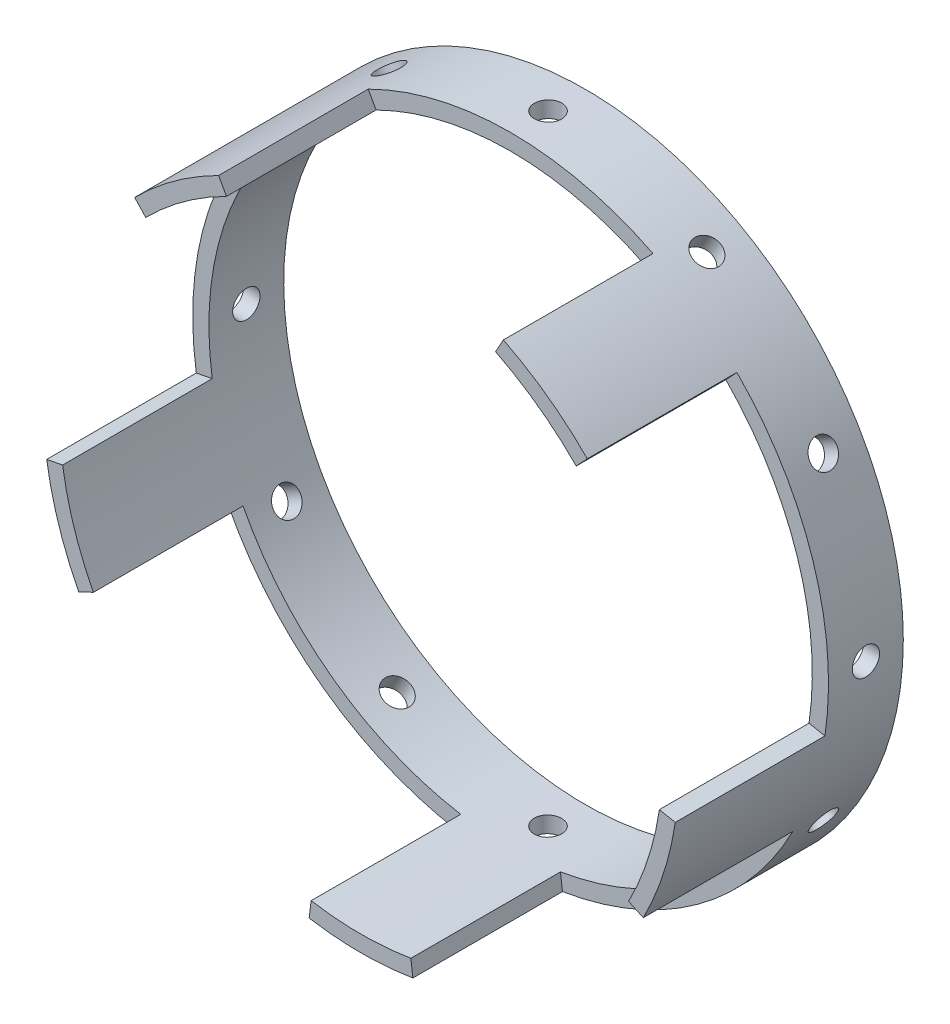
from build123d import *
from build123d.topology import SkipClean

# Parameters (mm, degrees)
SKETCH1_R           = 80.9625
SKETCH1_R_2         = 76.835
BOSS_EXTRUDE1_DEPTH = 19.05
BOSS_EXTRUDE2_DEPTH = 38.1
SKETCH2_R           = 3.478244762
CUT_EXTRUDE1_DEPTH  = 128.968649725
CIRPATTERN1_COUNT   = 12


with BuildPart() as part:
    # Sketch1 → Boss-Extrude1 (new body)
    with BuildSketch(Plane.XY):
        Circle(SKETCH1_R)
        Circle(SKETCH1_R_2, mode=Mode.SUBTRACT)
    extrude(amount=BOSS_EXTRUDE1_DEPTH)

    # Sketch3 → Boss-Extrude2 (add)
    with SkipClean():  # the faces are left unmerged after this step: merging them gives an invalid solid
        with BuildSketch(Plane.XY.offset(19.05)):
            with BuildLine():
                Line((-13.208, -79.877876426), (-12.7, -75.778144771))
                ThreePointArc((-12.7, -75.778144771), (0, -76.835), (12.7, -75.778144771))
                Line((12.7, -75.778144771), (13.208, -79.877876426))
                ThreePointArc((13.208, -79.877876426), (0, -80.9625), (-13.208, -79.877876426))
            make_face()
            with BuildLine():
                Line((-68.144782549, -35.495152294), (-71.886878421, -37.245175757))
                ThreePointArc((-71.886878421, -37.245175757), (-76.999913201, -25.018788407), (-80.049871344, -12.122066823))
                Line((-80.049871344, -12.122066823), (-75.993814206, -11.33831678))
                ThreePointArc((-75.993814206, -11.33831678), (-73.07442743, -23.743320763), (-68.144782549, -35.495152294))
            make_face()
            with BuildLine():
                Line((-54.815791771, 53.840934218), (-57.636534209, 56.859091891))
                ThreePointArc((-57.636534209, 56.859091891), (-47.588563489, 65.500038407), (-36.265541286, 72.386027115))
                Line((-36.265541286, 72.386027115), (-34.266760114, 68.770679626))
                ThreePointArc((-34.266760114, 68.770679626), (-45.16247986, 62.160820763), (-54.815791771, 53.840934218))
            make_face()
            with BuildLine():
                Line((34.266760114, 68.770679626), (36.265541286, 72.386027115))
                ThreePointArc((36.265541286, 72.386027115), (47.588563489, 65.500038407), (57.636534209, 56.859091891))
                Line((57.636534209, 56.859091891), (54.815791771, 53.840934218))
                ThreePointArc((54.815791771, 53.840934218), (45.16247986, 62.160820763), (34.266760114, 68.770679626))
            make_face()
            with BuildLine():
                Line((75.993814206, -11.33831678), (80.049871344, -12.122066823))
                ThreePointArc((80.049871344, -12.122066823), (76.999913201, -25.018788407), (71.886878421, -37.245175757))
                Line((71.886878421, -37.245175757), (68.144782549, -35.495152294))
                ThreePointArc((68.144782549, -35.495152294), (73.07442743, -23.743320763), (75.993814206, -11.33831678))
            make_face()
        extrude(amount=BOSS_EXTRUDE2_DEPTH)

    # Sketch2 → Cut-Extrude1 (cut, through all)
    with SkipClean():  # the faces are left unmerged after this step: merging them gives an invalid solid
        with BuildSketch(Plane(origin=(0, 0, 0), x_dir=(1, 0, 0), z_dir=(0, 1, 0))):
            with Locations((0, -9.525)):
                Circle(SKETCH2_R)
        cut_extrude1 = extrude(amount=-CUT_EXTRUDE1_DEPTH, mode=Mode.SUBTRACT)

    # CirPattern1: Cut-Extrude1 ×12 about axis
    with SkipClean():  # the faces are left unmerged after this step: merging them gives an invalid solid
        cirpattern1_axis = Axis((0, 0, 2.080715754), (0, 0, 1))
        for i in range(1, CIRPATTERN1_COUNT):
            add(cut_extrude1.rotate(cirpattern1_axis, i * 360 / CIRPATTERN1_COUNT), mode=Mode.SUBTRACT)


solid = part.part
